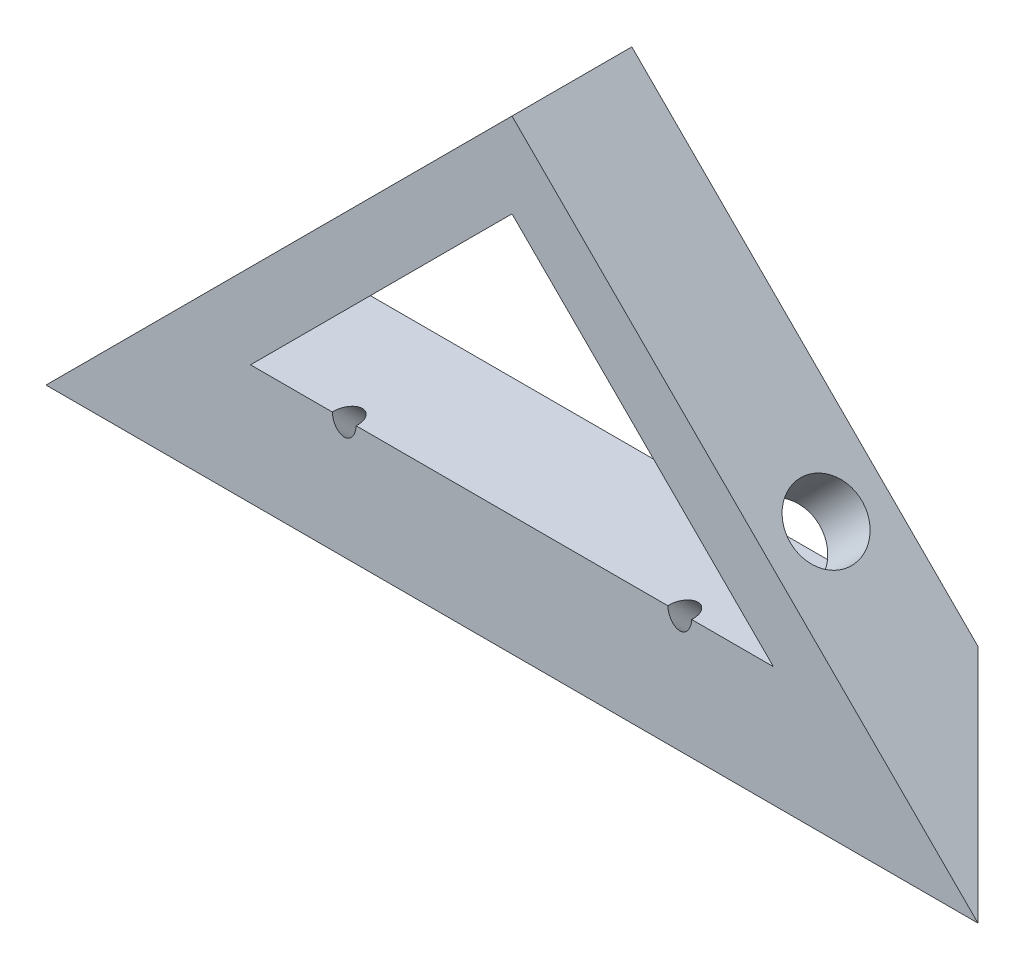
from build123d import *

# Parameters (mm, degrees)
BOSS_EXTRUDE4_DEPTH     = 10
CUT_EXTRUDE2_DEPTH      = 39.890872965
CUT_EXTRUDE2_DEPTH_BACK = 39.890872965
CUT_EXTRUDE3_REACH      = 57
SKETCH7_R               = 3
CUT_EXTRUDE4_REACH      = 57
SKETCH8_R               = 3
CUT_EXTRUDE5_REACH      = 29.5
SKETCH9_R               = 1


with BuildPart() as part:
    # Sketch4 → Boss-Extrude4 (new body)
    with BuildSketch(Plane.XY):
        Polygon((38.890872965, -10), (0, 28.890872965), (-38.890872965, -10), align=None)
        Polygon((0, 21.819805153), (21.819805153, 0), (14.748737342, 0), (-14.748737342, 0), (-21.819805153, 0), align=None, mode=Mode.SUBTRACT)
    extrude(amount=BOSS_EXTRUDE4_DEPTH)

    # Sketch6 → Cut-Extrude2 (cut, two sides)
    with BuildSketch(Plane(origin=(0, 0, 0), x_dir=(0, 0, -1), z_dir=(1, 0, 0))) as cut_extrude2_sk:
        Polygon((-10, -10), (0, 0), (0, -10), align=None)
    extrude(amount=CUT_EXTRUDE2_DEPTH, mode=Mode.SUBTRACT)
    extrude(cut_extrude2_sk.sketch, amount=-CUT_EXTRUDE2_DEPTH_BACK, mode=Mode.SUBTRACT)

    # Sketch7 → Cut-Extrude3 (cut, up to next)
    with BuildSketch(Plane(origin=(-14.445436483, 14.445436483, 0), x_dir=(0, 0, 1), z_dir=(-0.707106781, 0.707106781, 0)), mode=Mode.PRIVATE) as cut_extrude3_sk1:
        with Locations((5, -9.571067812)):
            Circle(SKETCH7_R)
    cut_extrude3_tool1 = extrude(cut_extrude3_sk1.sketch, amount=-CUT_EXTRUDE3_REACH, mode=Mode.PRIVATE) & part.part
    add(cut_extrude3_tool1.solids().sort_by_distance((-21.213203, 7.67767, 5))[0], mode=Mode.SUBTRACT)

    # Sketch8 → Cut-Extrude4 (cut, up to next)
    with BuildSketch(Plane(origin=(14.445436483, 14.445436483, 0), x_dir=(0, 0, -1), z_dir=(0.707106781, 0.707106781, 0)), mode=Mode.PRIVATE) as cut_extrude4_sk1:
        with Locations((-5, -9.571067812)):
            Circle(SKETCH8_R)
    cut_extrude4_tool1 = extrude(cut_extrude4_sk1.sketch, amount=-CUT_EXTRUDE4_REACH, mode=Mode.PRIVATE) & part.part
    add(cut_extrude4_tool1.solids().sort_by_distance((21.213203, 7.67767, 5))[0], mode=Mode.SUBTRACT)

    # Sketch9 → Cut-Extrude5 (cut, up to next)
    with BuildSketch(Plane(origin=(0, 0, 0), x_dir=(1, 0, 0), z_dir=(0, -0.707106781, -0.707106781)), mode=Mode.PRIVATE) as cut_extrude5_sk1:
        with Locations((-14, 7)):
            Circle(SKETCH9_R)
    cut_extrude5_tool1 = extrude(cut_extrude5_sk1.sketch, amount=-CUT_EXTRUDE5_REACH, mode=Mode.PRIVATE) & part.part
    add(cut_extrude5_tool1.solids().sort_by_distance((-14, -4.949747, 4.949747))[0], mode=Mode.SUBTRACT)
    # Sketch9 → Cut-Extrude5 (cut, up to next)
    with BuildSketch(Plane(origin=(0, 0, 0), x_dir=(1, 0, 0), z_dir=(0, -0.707106781, -0.707106781)), mode=Mode.PRIVATE) as cut_extrude5_sk2:
        with Locations((14, 7)):
            Circle(SKETCH9_R)
    cut_extrude5_tool2 = extrude(cut_extrude5_sk2.sketch, amount=-CUT_EXTRUDE5_REACH, mode=Mode.PRIVATE) & part.part
    add(cut_extrude5_tool2.solids().sort_by_distance((14, -4.949747, 4.949747))[0], mode=Mode.SUBTRACT)


solid = part.part
